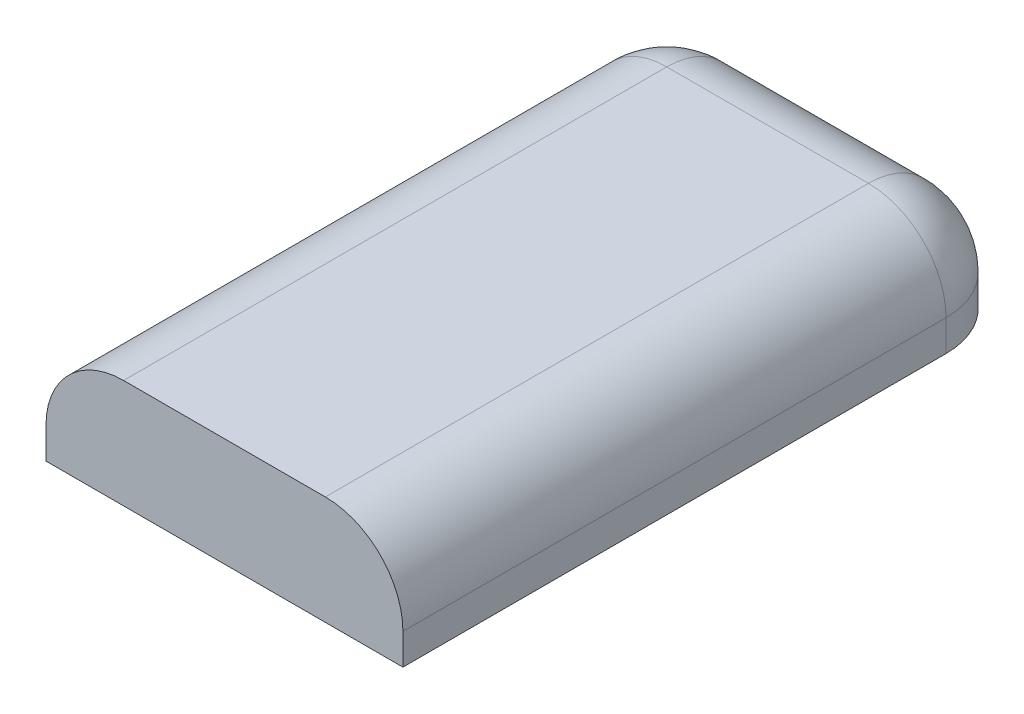
from build123d import *

# Parameters (mm, degrees)
SKETCH1_W           = 23
SKETCH1_H           = 40
BOSS_EXTRUDE1_DEPTH = 7
FILLET1_R           = 5
FILLET2_R           = 5
FILLET3_R           = 5


with BuildPart() as part:
    # Sketch1 → Boss-Extrude1 (new body)
    with BuildSketch(Plane(origin=(0, 0, 0), x_dir=(1, 0, 0), z_dir=(0, 1, 0))):
        Rectangle(SKETCH1_W, SKETCH1_H)
    extrude(amount=BOSS_EXTRUDE1_DEPTH)

    # Fillet1
    fillet1_edges = [part.edges().sort_by_distance(p)[0] for p in [
        (-11.5, 3.5, -20),
    ]]
    fillet(fillet1_edges, radius=FILLET1_R)

    # Fillet2
    fillet2_edges = [part.edges().sort_by_distance(p)[0] for p in [
        (11.5, 3.5, -20),
    ]]
    fillet(fillet2_edges, radius=FILLET2_R)

    # Fillet3
    fillet3_edges = [part.edges().sort_by_distance(p)[0] for p in [
        (-11.5, 7, 2.5),
        (-10.035533906, 7, -18.535533906),
        (0, 7, -20),
        (10.035533906, 7, -18.535533906),
        (11.5, 7, 2.5),
    ]]
    fillet(fillet3_edges, radius=FILLET3_R)


solid = part.part
